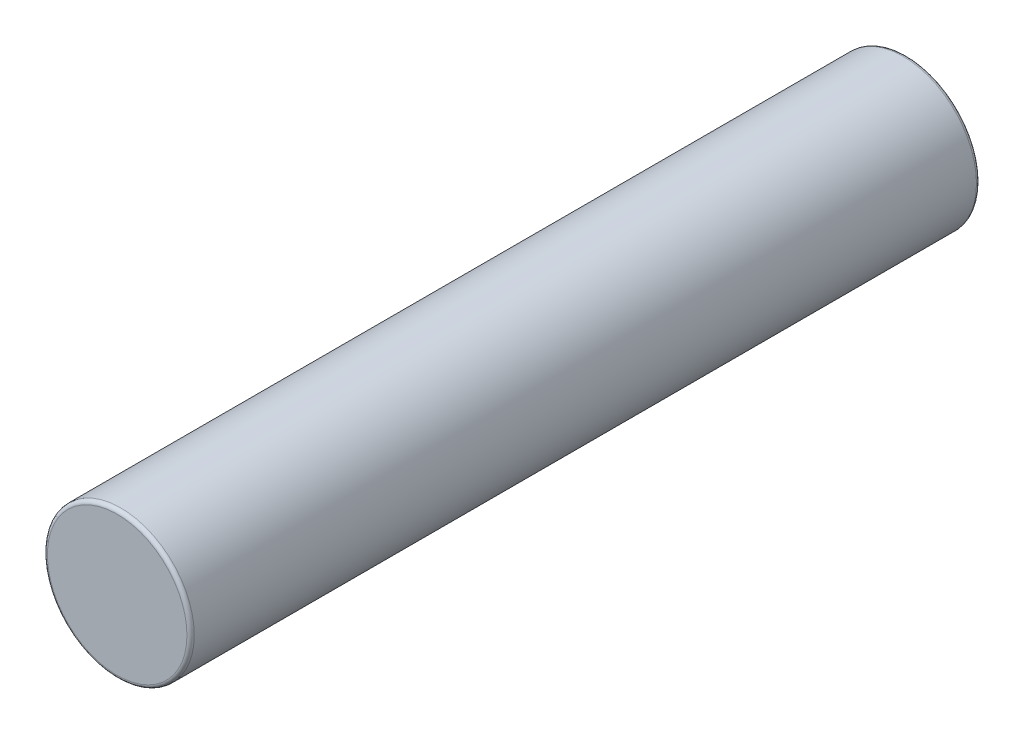
from build123d import *

# Parameters (mm, degrees)
SKETCH1_R           = 2
BOSS_EXTRUDE1_DEPTH = 21.5
FILLET1_R           = 0.1


with BuildPart() as part:
    # Sketch1 → Boss-Extrude1 (new body)
    with BuildSketch(Plane.XY):
        Circle(SKETCH1_R)
    extrude(amount=BOSS_EXTRUDE1_DEPTH)

    # Fillet1
    fillet1_edges = [part.edges().sort_by_distance(p)[0] for p in [
        (-2, 0, 0),
        (-2, 0, 21.5),
    ]]
    fillet(fillet1_edges, radius=FILLET1_R)


solid = part.part
